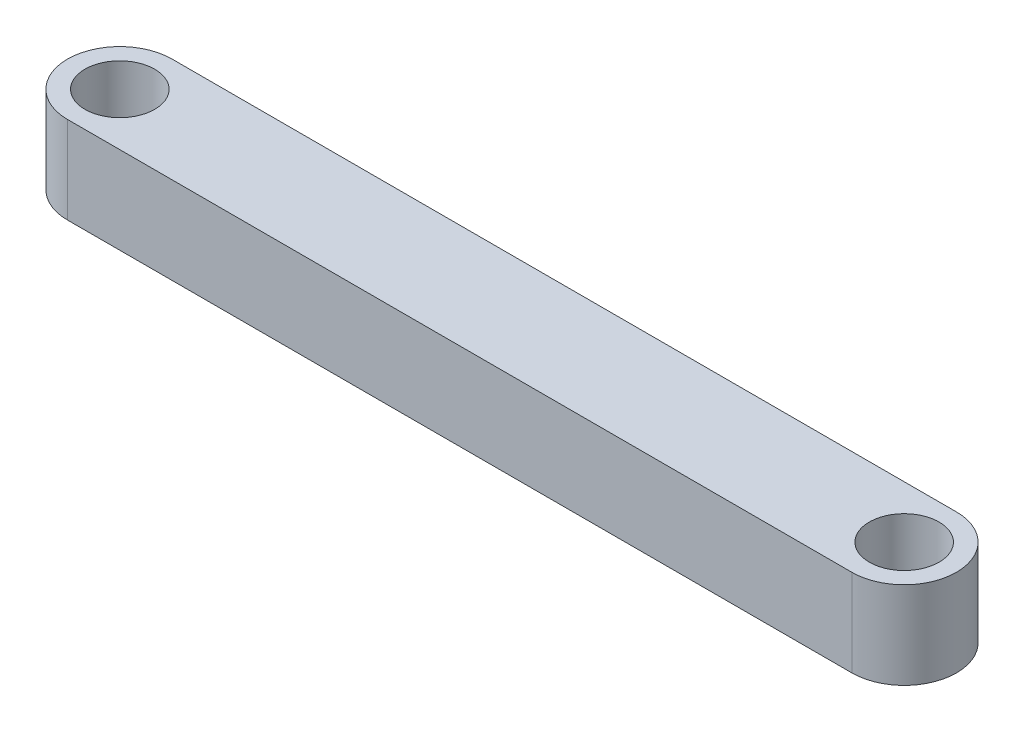
from build123d import *

# Parameters (mm, degrees)
SKETCH1_R           = 2
BOSS_EXTRUDE1_DEPTH = 5


with BuildPart() as part:
    # Sketch1 → Boss-Extrude1 (new body)
    with BuildSketch(Plane(origin=(0, 0, 0), x_dir=(1, 0, 0), z_dir=(0, 1, 0))):
        with BuildLine():
            Line((-22.5, 3), (22.5, 3))
            ThreePointArc((22.5, 3), (25.5, 0), (22.5, -3))
            Line((22.5, -3), (-22.5, -3))
            ThreePointArc((-22.5, -3), (-25.5, 0), (-22.5, 3))
        make_face()
        with Locations((-22.5, 0)):
            Circle(SKETCH1_R, mode=Mode.SUBTRACT)
        with Locations((22.5, 0)):
            Circle(SKETCH1_R, mode=Mode.SUBTRACT)
    extrude(amount=BOSS_EXTRUDE1_DEPTH)


solid = part.part
